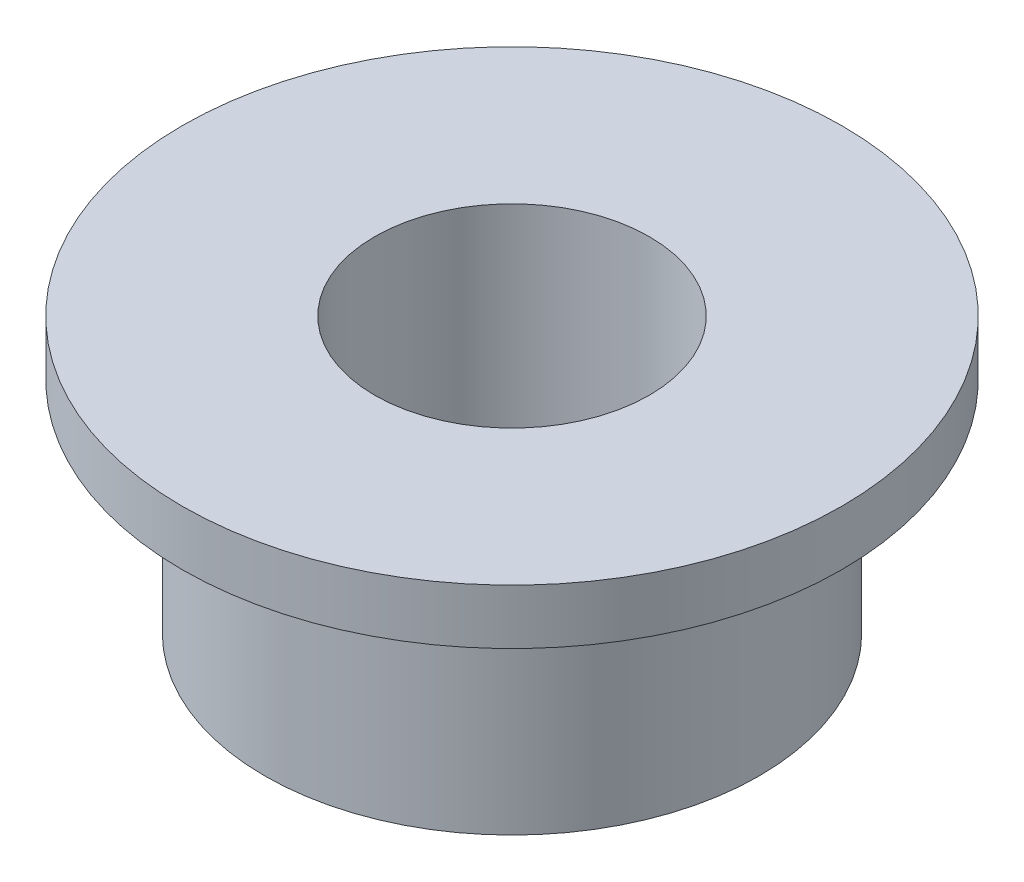
from build123d import *


with BuildPart() as part:
    # Sketch1 → Revolve1 (revolve)
    with BuildSketch(Plane.XY):
        Polygon((0, 0), (15, 0), (15, 10), (-20, 10), (-20, -40), (0, -40), align=None)
    revolve(axis=Axis((-45, -15, 0), (0, -1, 0)))


solid = part.part
